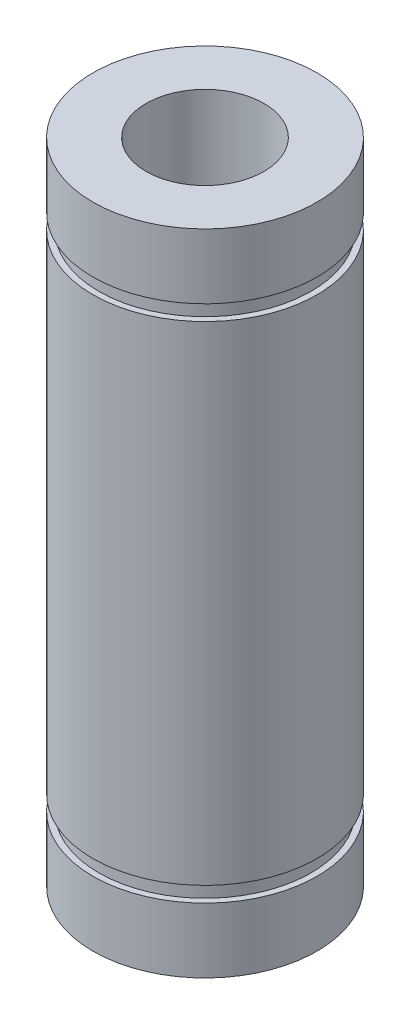
from build123d import *


with BuildPart() as part:
    # Sketch1 → Revolve1 (revolve)
    with BuildSketch(Plane.XY):
        Polygon((5, 27.5), (9.5, 27.5), (9.5, 22), (9, 22), (9, 20.7), (9.5, 20.7), (9.5, -20.7), (9, -20.7), (9, -22), (9.5, -22), (9.5, -27.5), (5, -27.5), align=None)
    revolve(axis=Axis((0, 46.044618834, 0), (0, -1, 0)))


solid = part.part
